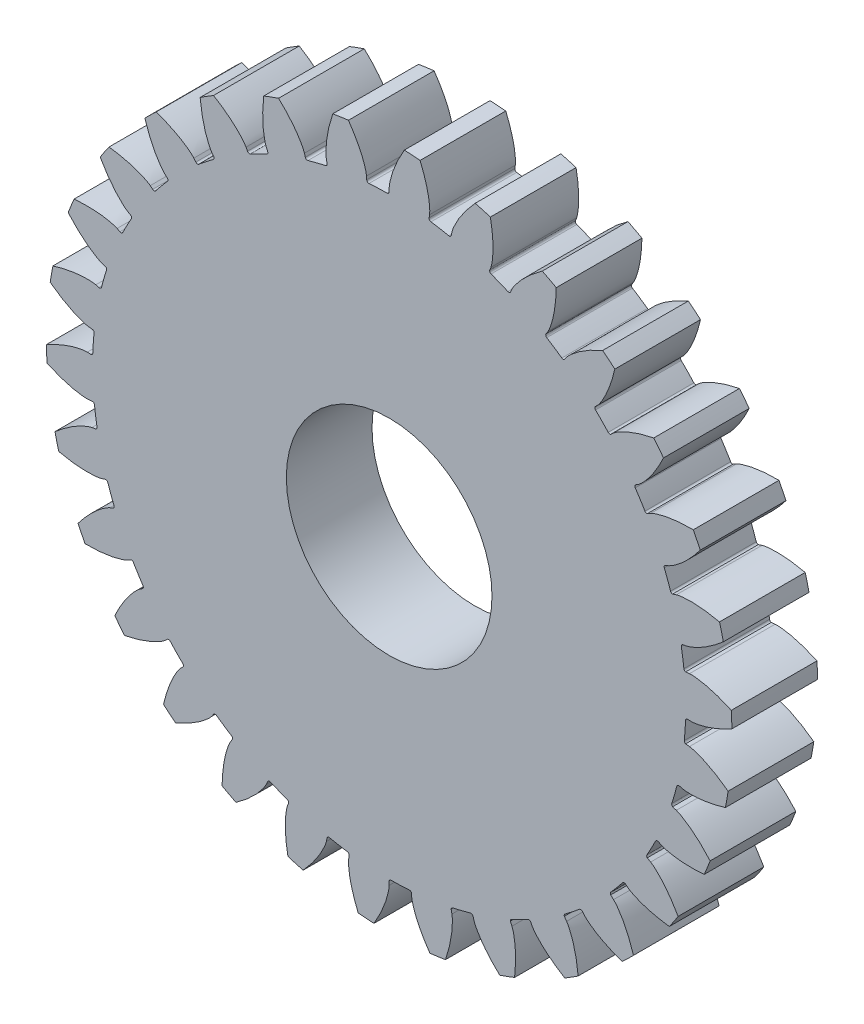
from build123d import *

# Parameters (mm, degrees)
CROQUIS2_R              = 6
SALIENTE_EXTRUIR1_DEPTH = 5
MATRIZC6_COUNT          = 30


with BuildPart() as part:
    # Croquis2 → Saliente-Extruir1 (new body)
    with BuildSketch(Plane.XY):
        with BuildLine():
            Line((0, 17.391052591), (0, 17.61923664))
            add(Edge.make_bspline(
                [(0, 17.61923664), (0.002968389, 17.708678911), (0.030865619, 17.908423079), (0.110728878, 18.25740541), (0.25502818, 18.704841344), (0.488882061, 19.262091692), (0.716792081, 19.695707807), (0.862564894, 19.944247124), (0.88412324, 19.980448596)],
                knots=[0, 0, 0, 0, 0.049384323, 0.111112812, 0.197532517, 0.308643471, 0.44444569, 0.467706461, 0.467706461, 0.467706461, 0.467706461], degree=3))
            ThreePointArc((0.88412324, 19.980448596), (1.344285858, 19.954771247), (1.80373463, 19.918497468))
            add(Edge.make_bspline(
                [(2.363172784, 17.460037633), (2.372227624, 17.549069881), (2.371373063, 17.75075096), (2.33903852, 18.10729168), (2.256055196, 18.57003888), (2.099055278, 19.153619735), (1.931363125, 19.613886239), (1.820242679, 19.879731591), (1.80373463, 19.918497468)],
                knots=[0, 0, 0, 0, 0.049384323, 0.111112812, 0.197532517, 0.308643471, 0.44444569, 0.467706461, 0.467706461, 0.467706461, 0.467706461], degree=3))
            Line((2.363172784, 17.460037633), (2.332489759, 17.275351458))
            ThreePointArc((2.332489759, 17.275351458), (2.354972763, 17.180980546), (2.438186458, 17.131112365))
            ThreePointArc((2.438186458, 17.131112365), (-1.163059321, -17.264618649), (-0.118452851, 17.303344561))
            ThreePointArc((-0.118452851, 17.303344561), (-0.044924166, 17.327882859), (0, 17.391052591))
        make_face()
        Circle(CROQUIS2_R, mode=Mode.SUBTRACT)
    saliente_extruir1 = extrude(amount=SALIENTE_EXTRUIR1_DEPTH)

    # MatrizC6: Saliente-Extruir1 ×30 about axis
    matrizc6_axis = Axis((0, 0, 5), (0, 0, -1))
    for i in range(1, MATRIZC6_COUNT):
        add(saliente_extruir1.rotate(matrizc6_axis, i * 360 / MATRIZC6_COUNT))


solid = part.part
